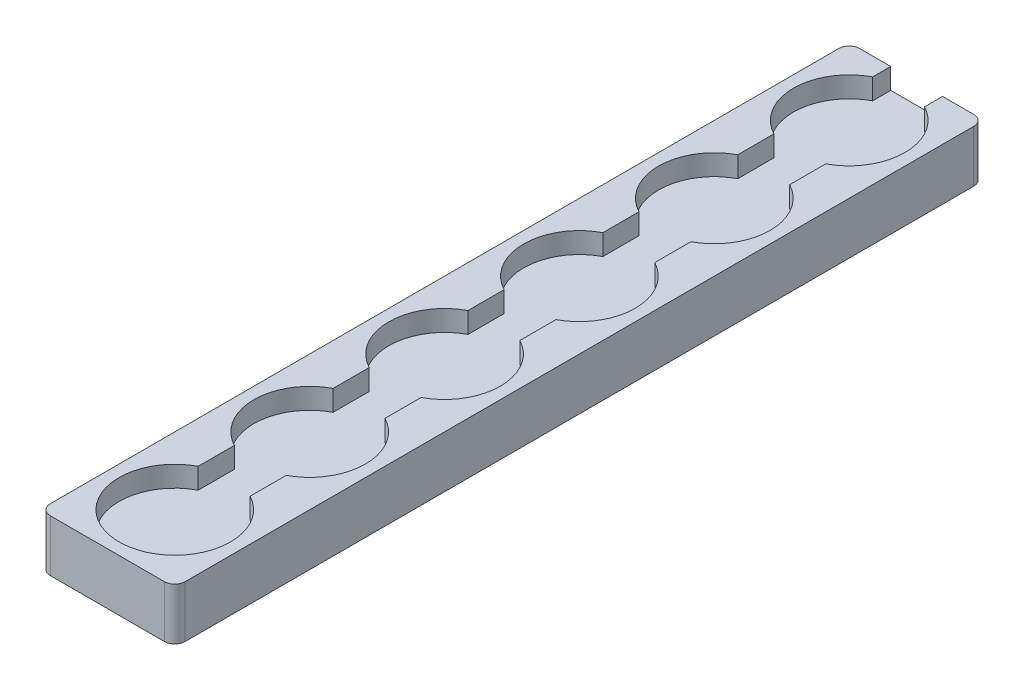
from build123d import *

# Parameters (mm, degrees)
SKETCH5_W           = 26
SKETCH5_H           = 26
BOSS_EXTRUDE1_DEPTH = 10
SKETCH4_R           = 10.75
CUT_EXTRUDE1_DEPTH  = 4
SKETCH6_W           = 10
SKETCH6_H           = 3.483566845
CUT_EXTRUDE2_DEPTH  = 4
LPATTERN1_COUNT     = 6
LPATTERN1_PITCH     = 26
SKETCH7_W           = 10
SKETCH7_H           = 4
CUT_EXTRUDE3_DEPTH  = 131
FILLET1_R           = 2
SKETCH9_W           = 8
SKETCH9_H           = 3
CUT_EXTRUDE4_DEPTH  = 3


with BuildPart() as part:
    # Sketch5 → Boss-Extrude1 (new body)
    with BuildSketch(Plane(origin=(0, 0, 0), x_dir=(1, 0, 0), z_dir=(0, 1, 0))):
        Rectangle(SKETCH5_W, SKETCH5_H)
    boss_extrude1 = extrude(amount=-BOSS_EXTRUDE1_DEPTH)

    # Sketch4 → Cut-Extrude1 (cut)
    with BuildSketch(Plane(origin=(0, 0, 0), x_dir=(1, 0, 0), z_dir=(0, 1, 0))):
        Circle(SKETCH4_R)
    cut_extrude1 = extrude(amount=-CUT_EXTRUDE1_DEPTH, mode=Mode.SUBTRACT)

    # Sketch6 → Cut-Extrude2 (cut)
    with BuildSketch(Plane(origin=(0, 0, 0), x_dir=(1, 0, 0), z_dir=(0, 1, 0))):
        with Locations((0, 11.258216578)):
            Rectangle(SKETCH6_W, SKETCH6_H)
    cut_extrude2 = extrude(amount=-CUT_EXTRUDE2_DEPTH, mode=Mode.SUBTRACT)

    # LPattern1: Boss-Extrude1, Cut-Extrude1, Cut-Extrude2 ×6
    with Locations(*[(0, 0, -i * LPATTERN1_PITCH) for i in range(1, LPATTERN1_COUNT)]):
        add(boss_extrude1)
        add(cut_extrude1, mode=Mode.SUBTRACT)
        add(cut_extrude2, mode=Mode.SUBTRACT)

    # Sketch7 → Cut-Extrude3 (cut, through all)
    with BuildSketch(Plane.XY.offset(-13)):
        with Locations((0, -2)):
            Rectangle(SKETCH7_W, SKETCH7_H)
    extrude(amount=-CUT_EXTRUDE3_DEPTH, mode=Mode.SUBTRACT)

    # Fillet1
    fillet1_edges = [part.edges().sort_by_distance(p)[0] for p in [
        (13, -5, -143),
        (-13, -5, -143),
        (13, -5, 13),
        (-13, -5, 13),
    ]]
    fillet(fillet1_edges, radius=FILLET1_R)

    # Sketch9 → Cut-Extrude4 (cut)
    with BuildSketch(Plane(origin=(0, 0, -143), x_dir=(-1, 0, 0), z_dir=(0, 0, -1))):
        with Locations((0, -7)):
            Rectangle(SKETCH9_W, SKETCH9_H)
    extrude(amount=-CUT_EXTRUDE4_DEPTH, mode=Mode.SUBTRACT)


solid = part.part
